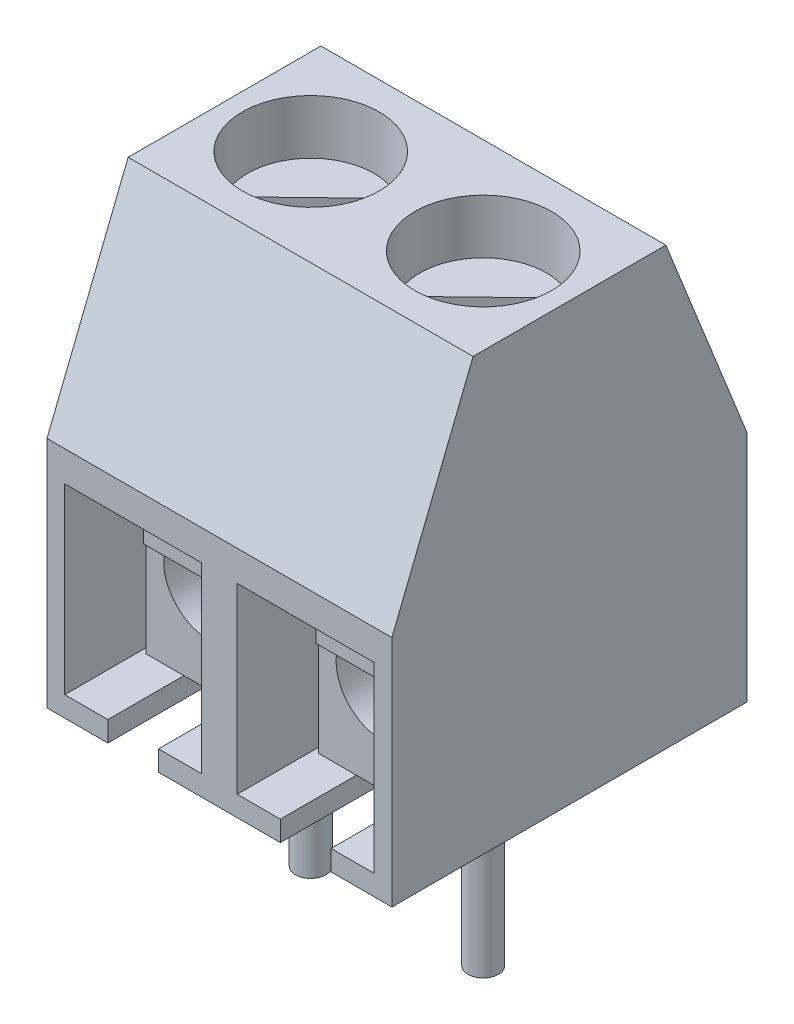
from build123d import *

# Parameters (mm, degrees)
BOSS_EXTRU_1_DEPTH         = 3.4
ENL_V_MAT_EXTRU_1_DEPTH    = 6
ESQUISSE3_R                = 1.35
ENL_V_MAT_EXTRU_2_DEPTH    = 4.6
BOSS_EXTRU_2_START         = -1
ESQUISSE4_R                = 1.25
BOSS_EXTRU_2_DEPTH         = 3.4
ENL_V_MAT_EXTRU_3_DEPTH    = 0.4
BOSS_EXTRU_3_START         = -1.5
ESQUISSE6_R                = 0.9
BOSS_EXTRU_3_DEPTH         = 4.5
ESQUISSE7_R                = 0.3
BOSS_EXTRU_4_DEPTH         = 4
EXTRU_MINCE1_DEPTH         = 0.7
R_P_TITION_LIN_AIRE2_COUNT = 2
R_P_TITION_LIN_AIRE2_PITCH = 3.4
R_P_TITION_LIN_AIRE3_COUNT = 2
R_P_TITION_LIN_AIRE3_PITCH = 3.4


with BuildPart() as part:
    # Esquisse1 → Boss.-Extru.1 (new body)
    with BuildSketch(Plane(origin=(0, 0, 0), x_dir=(0, 0, -1), z_dir=(1, 0, 0))):
        Polygon((0, 0), (0, 4.6), (1.6, 8.6), (5.4, 8.6), (7, 4.6), (7, 0), align=None)
    boss_extru_1 = extrude(amount=BOSS_EXTRU_1_DEPTH)

    # Esquisse2 → Enlèv. mat.-Extru.1 (cut)
    with BuildSketch(Plane.XY):
        Polygon((0.35, 0.4), (1.2, 0.4), (1.2, 0), (2.2, 0), (2.2, 0.4), (3.05, 0.4), (3.05, 4), (0.35, 4), align=None)
    enl_v_mat_extru_1 = extrude(amount=-ENL_V_MAT_EXTRU_1_DEPTH, mode=Mode.SUBTRACT)

    # Esquisse3 → Enlèv. mat.-Extru.2 (cut)
    with BuildSketch(Plane(origin=(0, 8.6, 0), x_dir=(1, 0, 0), z_dir=(0, 1, 0))):
        with Locations(Location((1.7, 3.5, 0), (0, 0, 270))):  # turned: the seam where the file's is
            Circle(ESQUISSE3_R)
    enl_v_mat_extru_2 = extrude(amount=-ENL_V_MAT_EXTRU_2_DEPTH, mode=Mode.SUBTRACT)

    # Répétition linéaire2: Boss.-Extru.1, Enlèv. mat.-Extru.1, Enlèv. mat.-Extru.2 ×2
    with Locations(*[(i * R_P_TITION_LIN_AIRE2_PITCH, 0, 0) for i in range(1, R_P_TITION_LIN_AIRE2_COUNT)]):
        add(boss_extru_1)
        add(enl_v_mat_extru_1, mode=Mode.SUBTRACT)
        add(enl_v_mat_extru_2, mode=Mode.SUBTRACT)


with BuildPart() as body_2:
    # Esquisse4 → Boss.-Extru.2 (new body)
    with BuildSketch(Plane(origin=(0, 8.6, 0), x_dir=(1, 0, 0), z_dir=(0, 1, 0)).offset(BOSS_EXTRU_2_START)):
        with Locations(Location((1.7, 3.5, 0), (0, 0, 270))):  # turned: the seam where the file's is
            Circle(ESQUISSE4_R)
    extrude(amount=-BOSS_EXTRU_2_DEPTH)

    # Esquisse5 → Enlèv. mat.-Extru.3 (cut)
    with BuildSketch(Plane(origin=(0, 7.6, 0), x_dir=(1, 0, 0), z_dir=(0, 1, 0))):
        with BuildLine():
            Line((0.61870802, 2.87285755), (2.364496958, 4.558746331))
            ThreePointArc((2.364496958, 4.558746331), (2.59917475, 4.368322963), (2.78129198, 4.12714245))
            Line((2.78129198, 4.12714245), (1.035503042, 2.441253669))
            ThreePointArc((1.035503042, 2.441253669), (0.80082525, 2.631677037), (0.61870802, 2.87285755))
        make_face()
    extrude(amount=-ENL_V_MAT_EXTRU_3_DEPTH, mode=Mode.SUBTRACT)


with BuildPart() as body_3:
    # Esquisse6 → Boss.-Extru.3 (new body)
    with BuildSketch(Plane.XY.offset(BOSS_EXTRU_3_START)):
        Polygon((0.45, 0.4), (2.95, 0.4), (2.95, 3.9), (2.45, 3.9), (2.45, 3.65), (0.95, 3.65), (0.95, 3.9), (0.45, 3.9), align=None)
        with Locations((1.7, 2.15)):
            Circle(ESQUISSE6_R, mode=Mode.SUBTRACT)
    extrude(amount=-BOSS_EXTRU_3_DEPTH)

    # Esquisse7 → Boss.-Extru.4 (add)
    with BuildSketch(Plane.XZ.offset(-0.4)):
        with Locations((1.7, -3.5)):
            Circle(ESQUISSE7_R)
    extrude(amount=BOSS_EXTRU_4_DEPTH)


with BuildPart() as body_4:
    # Esquisse8 → Extru.-Mince1 (new body, symmetric)
    with BuildSketch(Plane(origin=(1.7, 0, 0), x_dir=(0, 0, -1), z_dir=(1, 0, 0))):
        with BuildLine():
            Line((2.15, 3.9), (1.5, 3.9))
            ThreePointArc((1.5, 3.9), (1.075735931, 3.724264069), (0.9, 3.3))
            Line((0.9, 3.3), (0.9, 2.853369234))
            Line((0.9, 2.853369234), (2.391205681, 1.602099097))
            Line((2.391205681, 1.602099097), (2.519763203, 1.755307986))
            Line((2.519763203, 1.755307986), (1.1, 2.946630766))
            Line((1.1, 2.946630766), (1.1, 3.3))
            ThreePointArc((1.1, 3.3), (1.217157288, 3.582842712), (1.5, 3.7))
            Line((1.5, 3.7), (2.15, 3.7))
            Line((2.15, 3.7), (2.15, 3.9))
        make_face()
    extrude(amount=EXTRU_MINCE1_DEPTH, both=True)


with BuildPart() as r_p_tition_lin_aire3_1:
    # Répétition linéaire3: pattern copy
    add(body_2.part.moved(Location(Vector(1, 0, 0) * (1 * R_P_TITION_LIN_AIRE3_PITCH))))


with BuildPart() as r_p_tition_lin_aire3_2:
    # Répétition linéaire3: pattern copy
    add(body_4.part.moved(Location(Vector(1, 0, 0) * (1 * R_P_TITION_LIN_AIRE3_PITCH))))


with BuildPart() as r_p_tition_lin_aire3_3:
    # Répétition linéaire3: pattern copy
    add(body_3.part.moved(Location(Vector(1, 0, 0) * (1 * R_P_TITION_LIN_AIRE3_PITCH))))


solid = Compound([part.part, body_2.part, body_3.part, body_4.part, r_p_tition_lin_aire3_1.part, r_p_tition_lin_aire3_2.part, r_p_tition_lin_aire3_3.part])
